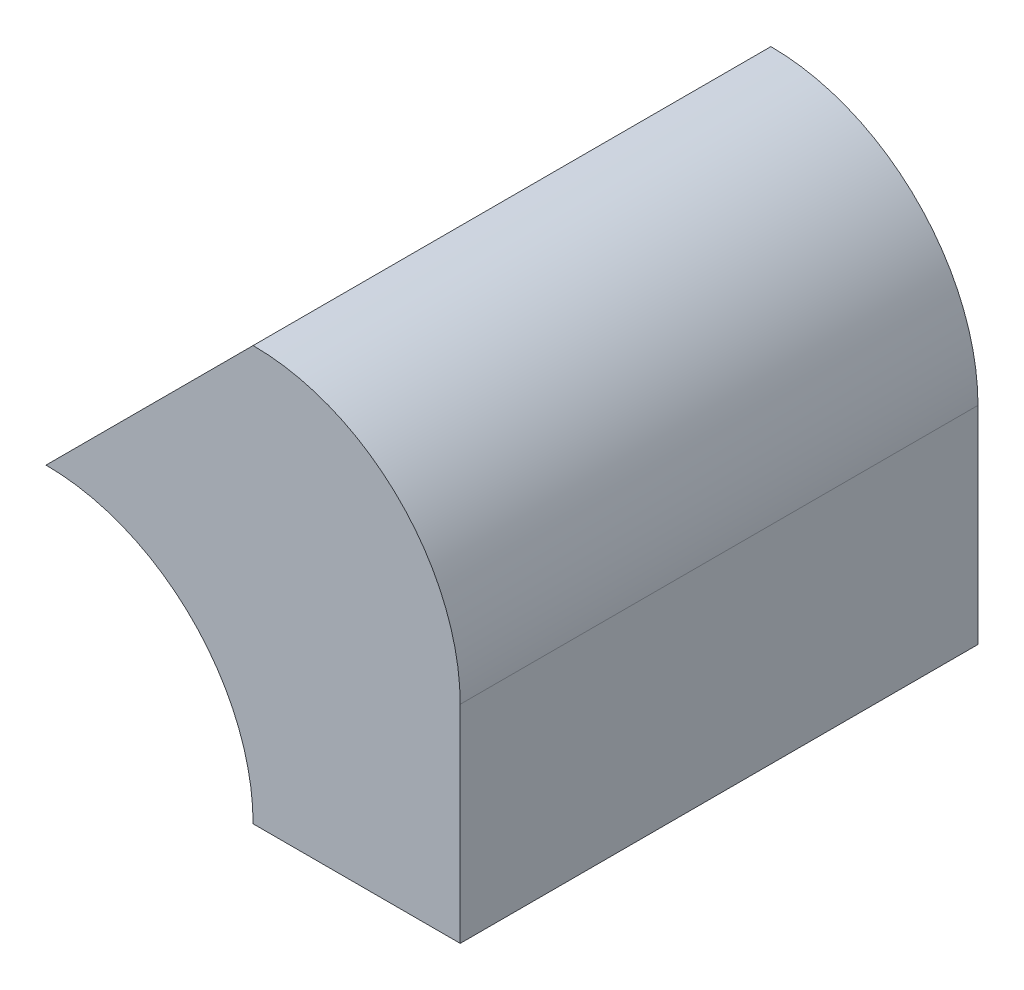
from build123d import *

# Parameters (mm, degrees)
BOSS_EXTRUDE1_DEPTH = 25


with BuildPart() as part:
    # Sketch1 → Boss-Extrude1 (new body)
    with BuildSketch(Plane.XY):
        with BuildLine():
            Line((-10, 0), (0, 0))
            Line((0, 0), (0, 10))
            ThreePointArc((0, 10), (-2.928932188, 17.071067812), (-10, 20))
            Line((-10, 20), (-20, 10))
            ThreePointArc((-20, 10), (-12.928932188, 7.071067812), (-10, 0))
        make_face()
    extrude(amount=BOSS_EXTRUDE1_DEPTH)


solid = part.part
